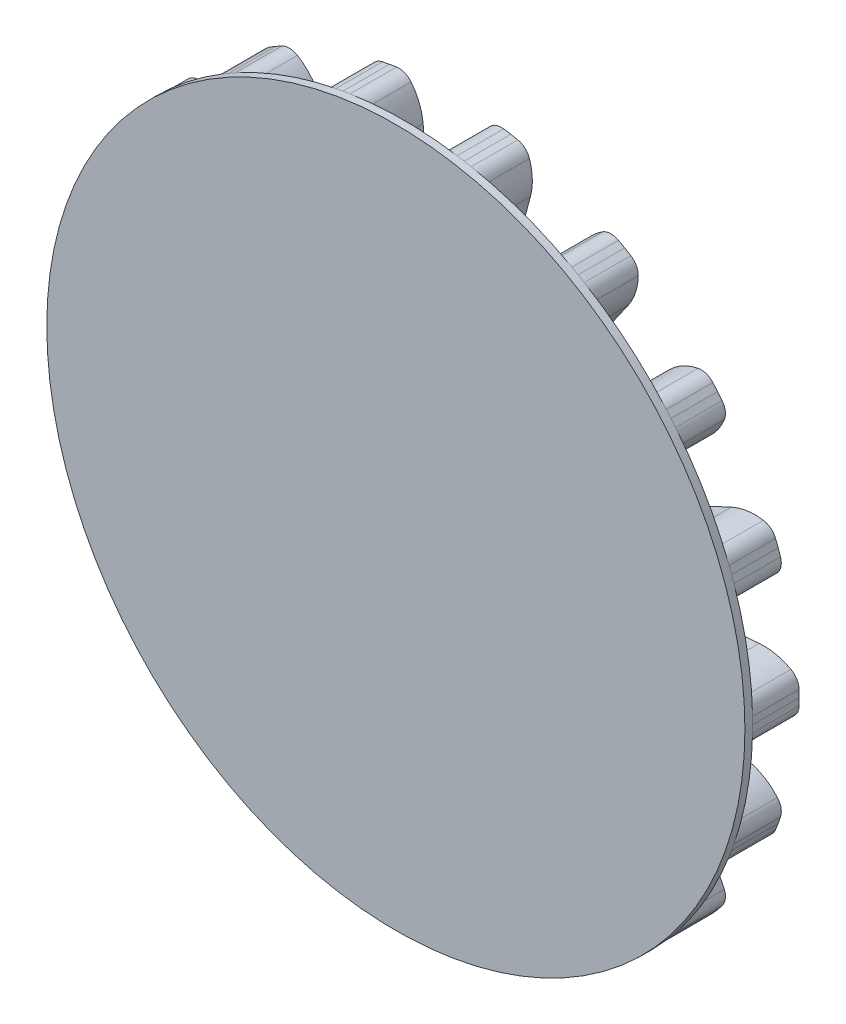
from build123d import *

# Parameters (mm, degrees)
BOSS_EXTRU_4_DEPTH           = 3
CONG_1_R                     = 0.7
CONG_2_R                     = 1
R_P_TITION_CIRCULAIRE1_COUNT = 18
ESQUISSE5_R                  = 2.5
ENL_V_MAT_EXTRU_1_DEPTH      = 32.778381009
ENL_V_MAT_EXTRU_2_DEPTH      = 32.778381009
ESQUISSE7_R                  = 4.018452413
ENL_V_MAT_EXTRU_3_DEPTH      = 10
ESQUISSE8_R                  = 22.5
BOSS_EXTRU_5_DEPTH           = 0.5


with BuildPart() as part:
    # Esquisse4 → Boss.-Extru.4 (new body)
    with BuildSketch(Plane.XY):
        with BuildLine():
            ThreePointArc((17.433407217, -1.525225498), (17.350285074, -2.284208364), (17.234135678, -3.038843109))
            Line((17.234135678, -3.038843109), (0, 0))
            Line((0, 0), (17.234135678, 3.038843109))
            ThreePointArc((17.234135678, 3.038843109), (17.350285074, 2.284208364), (17.433407217, 1.525225498))
            Line((17.433407217, 1.525225498), (19.923893962, 1.743114855))
            ThreePointArc((19.923893962, 1.743114855), (21.273894998, 1.605964155), (22.478584986, 0.981436216))
            Line((22.478584986, 0.981436216), (22.5, 0))
            Line((22.5, 0), (22.478584986, -0.981436216))
            ThreePointArc((22.478584986, -0.981436216), (21.273894998, -1.605964155), (19.923893962, -1.743114855))
            Line((19.923893962, -1.743114855), (17.433407217, -1.525225498))
        make_face()
    extrude(amount=BOSS_EXTRU_4_DEPTH)

    # Congé1
    cong_1_edges = [part.edges().sort_by_distance(p)[0] for p in [
        (17.433407217, 1.525225498, 1.5),
        (17.433407217, -1.525225498, 1.5),
    ]]
    fillet(cong_1_edges, radius=CONG_1_R)

    # Congé2
    cong_2_edges = [part.edges().sort_by_distance(p)[0] for p in [
        (22.478584986, 0.981436216, 1.5),
        (22.478584986, -0.981436216, 1.5),
    ]]
    fillet(cong_2_edges, radius=CONG_2_R)


with BuildPart() as r_p_tition_circulaire1_1:
    # Répétition circulaire1: pattern copy
    add(part.part.rotate(Axis((0, 0, 0), (0, 0, 1)), 1 * 360 / R_P_TITION_CIRCULAIRE1_COUNT))


with BuildPart() as r_p_tition_circulaire1_2:
    # Répétition circulaire1: pattern copy
    add(part.part.rotate(Axis((0, 0, 0), (0, 0, 1)), 2 * 360 / R_P_TITION_CIRCULAIRE1_COUNT))


with BuildPart() as r_p_tition_circulaire1_3:
    # Répétition circulaire1: pattern copy
    add(part.part.rotate(Axis((0, 0, 0), (0, 0, 1)), 3 * 360 / R_P_TITION_CIRCULAIRE1_COUNT))


with BuildPart() as r_p_tition_circulaire1_4:
    # Répétition circulaire1: pattern copy
    add(part.part.rotate(Axis((0, 0, 0), (0, 0, 1)), 4 * 360 / R_P_TITION_CIRCULAIRE1_COUNT))


with BuildPart() as r_p_tition_circulaire1_5:
    # Répétition circulaire1: pattern copy
    add(part.part.rotate(Axis((0, 0, 0), (0, 0, 1)), 5 * 360 / R_P_TITION_CIRCULAIRE1_COUNT))


with BuildPart() as r_p_tition_circulaire1_6:
    # Répétition circulaire1: pattern copy
    add(part.part.rotate(Axis((0, 0, 0), (0, 0, 1)), 6 * 360 / R_P_TITION_CIRCULAIRE1_COUNT))


with BuildPart() as r_p_tition_circulaire1_7:
    # Répétition circulaire1: pattern copy
    add(part.part.rotate(Axis((0, 0, 0), (0, 0, 1)), 7 * 360 / R_P_TITION_CIRCULAIRE1_COUNT))


with BuildPart() as r_p_tition_circulaire1_8:
    # Répétition circulaire1: pattern copy
    add(part.part.rotate(Axis((0, 0, 0), (0, 0, 1)), 8 * 360 / R_P_TITION_CIRCULAIRE1_COUNT))


with BuildPart() as r_p_tition_circulaire1_9:
    # Répétition circulaire1: pattern copy
    add(part.part.rotate(Axis((0, 0, 0), (0, 0, 1)), 9 * 360 / R_P_TITION_CIRCULAIRE1_COUNT))


with BuildPart() as r_p_tition_circulaire1_10:
    # Répétition circulaire1: pattern copy
    add(part.part.rotate(Axis((0, 0, 0), (0, 0, 1)), 10 * 360 / R_P_TITION_CIRCULAIRE1_COUNT))


with BuildPart() as r_p_tition_circulaire1_11:
    # Répétition circulaire1: pattern copy
    add(part.part.rotate(Axis((0, 0, 0), (0, 0, 1)), 11 * 360 / R_P_TITION_CIRCULAIRE1_COUNT))


with BuildPart() as r_p_tition_circulaire1_12:
    # Répétition circulaire1: pattern copy
    add(part.part.rotate(Axis((0, 0, 0), (0, 0, 1)), 12 * 360 / R_P_TITION_CIRCULAIRE1_COUNT))


with BuildPart() as r_p_tition_circulaire1_13:
    # Répétition circulaire1: pattern copy
    add(part.part.rotate(Axis((0, 0, 0), (0, 0, 1)), 13 * 360 / R_P_TITION_CIRCULAIRE1_COUNT))


with BuildPart() as r_p_tition_circulaire1_14:
    # Répétition circulaire1: pattern copy
    add(part.part.rotate(Axis((0, 0, 0), (0, 0, 1)), 14 * 360 / R_P_TITION_CIRCULAIRE1_COUNT))


with BuildPart() as r_p_tition_circulaire1_15:
    # Répétition circulaire1: pattern copy
    add(part.part.rotate(Axis((0, 0, 0), (0, 0, 1)), 15 * 360 / R_P_TITION_CIRCULAIRE1_COUNT))


with BuildPart() as r_p_tition_circulaire1_16:
    # Répétition circulaire1: pattern copy
    add(part.part.rotate(Axis((0, 0, 0), (0, 0, 1)), 16 * 360 / R_P_TITION_CIRCULAIRE1_COUNT))


with BuildPart() as r_p_tition_circulaire1_17:
    # Répétition circulaire1: pattern copy
    add(part.part.rotate(Axis((0, 0, 0), (0, 0, 1)), 17 * 360 / R_P_TITION_CIRCULAIRE1_COUNT))


with BuildPart() as enl_v_mat_extru_1_tool:
    # Esquisse5 → Enlèv. mat.-Extru.1 (new, through all)
    with BuildSketch(Plane.XY.offset(3)):
        Circle(ESQUISSE5_R)
    extrude(amount=-ENL_V_MAT_EXTRU_1_DEPTH)


with BuildPart() as part_1:
    add(part.part)

    # Enlèv. mat.-Extru.1: cut by enl_v_mat_extru_1_tool
    add(enl_v_mat_extru_1_tool.part, mode=Mode.SUBTRACT)


with BuildPart() as r_p_tition_circulaire1_1_1:
    add(r_p_tition_circulaire1_1.part)

    # Enlèv. mat.-Extru.1: cut by enl_v_mat_extru_1_tool
    add(enl_v_mat_extru_1_tool.part, mode=Mode.SUBTRACT)


with BuildPart() as r_p_tition_circulaire1_2_1:
    add(r_p_tition_circulaire1_2.part)

    # Enlèv. mat.-Extru.1: cut by enl_v_mat_extru_1_tool
    add(enl_v_mat_extru_1_tool.part, mode=Mode.SUBTRACT)


with BuildPart() as r_p_tition_circulaire1_3_1:
    add(r_p_tition_circulaire1_3.part)

    # Enlèv. mat.-Extru.1: cut by enl_v_mat_extru_1_tool
    add(enl_v_mat_extru_1_tool.part, mode=Mode.SUBTRACT)


with BuildPart() as r_p_tition_circulaire1_4_1:
    add(r_p_tition_circulaire1_4.part)

    # Enlèv. mat.-Extru.1: cut by enl_v_mat_extru_1_tool
    add(enl_v_mat_extru_1_tool.part, mode=Mode.SUBTRACT)


with BuildPart() as r_p_tition_circulaire1_5_1:
    add(r_p_tition_circulaire1_5.part)

    # Enlèv. mat.-Extru.1: cut by enl_v_mat_extru_1_tool
    add(enl_v_mat_extru_1_tool.part, mode=Mode.SUBTRACT)


with BuildPart() as r_p_tition_circulaire1_6_1:
    add(r_p_tition_circulaire1_6.part)

    # Enlèv. mat.-Extru.1: cut by enl_v_mat_extru_1_tool
    add(enl_v_mat_extru_1_tool.part, mode=Mode.SUBTRACT)


with BuildPart() as r_p_tition_circulaire1_7_1:
    add(r_p_tition_circulaire1_7.part)

    # Enlèv. mat.-Extru.1: cut by enl_v_mat_extru_1_tool
    add(enl_v_mat_extru_1_tool.part, mode=Mode.SUBTRACT)


with BuildPart() as r_p_tition_circulaire1_8_1:
    add(r_p_tition_circulaire1_8.part)

    # Enlèv. mat.-Extru.1: cut by enl_v_mat_extru_1_tool
    add(enl_v_mat_extru_1_tool.part, mode=Mode.SUBTRACT)


with BuildPart() as r_p_tition_circulaire1_9_1:
    add(r_p_tition_circulaire1_9.part)

    # Enlèv. mat.-Extru.1: cut by enl_v_mat_extru_1_tool
    add(enl_v_mat_extru_1_tool.part, mode=Mode.SUBTRACT)


with BuildPart() as r_p_tition_circulaire1_10_1:
    add(r_p_tition_circulaire1_10.part)

    # Enlèv. mat.-Extru.1: cut by enl_v_mat_extru_1_tool
    add(enl_v_mat_extru_1_tool.part, mode=Mode.SUBTRACT)


with BuildPart() as r_p_tition_circulaire1_11_1:
    add(r_p_tition_circulaire1_11.part)

    # Enlèv. mat.-Extru.1: cut by enl_v_mat_extru_1_tool
    add(enl_v_mat_extru_1_tool.part, mode=Mode.SUBTRACT)


with BuildPart() as r_p_tition_circulaire1_12_1:
    add(r_p_tition_circulaire1_12.part)

    # Enlèv. mat.-Extru.1: cut by enl_v_mat_extru_1_tool
    add(enl_v_mat_extru_1_tool.part, mode=Mode.SUBTRACT)


with BuildPart() as r_p_tition_circulaire1_13_1:
    add(r_p_tition_circulaire1_13.part)

    # Enlèv. mat.-Extru.1: cut by enl_v_mat_extru_1_tool
    add(enl_v_mat_extru_1_tool.part, mode=Mode.SUBTRACT)


with BuildPart() as r_p_tition_circulaire1_14_1:
    add(r_p_tition_circulaire1_14.part)

    # Enlèv. mat.-Extru.1: cut by enl_v_mat_extru_1_tool
    add(enl_v_mat_extru_1_tool.part, mode=Mode.SUBTRACT)


with BuildPart() as r_p_tition_circulaire1_15_1:
    add(r_p_tition_circulaire1_15.part)

    # Enlèv. mat.-Extru.1: cut by enl_v_mat_extru_1_tool
    add(enl_v_mat_extru_1_tool.part, mode=Mode.SUBTRACT)


with BuildPart() as r_p_tition_circulaire1_16_1:
    add(r_p_tition_circulaire1_16.part)

    # Enlèv. mat.-Extru.1: cut by enl_v_mat_extru_1_tool
    add(enl_v_mat_extru_1_tool.part, mode=Mode.SUBTRACT)


with BuildPart() as r_p_tition_circulaire1_17_1:
    add(r_p_tition_circulaire1_17.part)

    # Enlèv. mat.-Extru.1: cut by enl_v_mat_extru_1_tool
    add(enl_v_mat_extru_1_tool.part, mode=Mode.SUBTRACT)


with BuildPart() as enl_v_mat_extru_2_tool:
    # Esquisse6 → Enlèv. mat.-Extru.2 (new, through all)
    with BuildSketch(Plane.XY.offset(3)):
        with BuildLine():
            Line((2.326636597, -14.696627841), (3.459323403, -2.287472159))
            add(Edge.make_bspline(
                [(3.459323403, -2.287472159), (3.509578647, -1.618115314), (3.610089136, -0.279401623), (3.193486845, 5.400258865), (2.634713817, 10.38131394), (2.150623403, 14.696627841)],
                knots=[0, 0, 0, 0, 0.117897148, 0.235794296, 1, 1, 1, 1], degree=3))
            add(Edge.make_bspline(
                [(2.150623403, 14.696627841), (2.095752738, 14.957223177), (1.986004569, 15.478446335), (1.479240929, 16.11915433), (0.795253054, 16.542773464), (0, 16.690346959), (-0.795253054, 16.542773464), (-1.479240929, 16.11915433), (-1.986004569, 15.478446335), (-2.095752738, 14.957223177), (-2.150623403, 14.696627841)],
                knots=[0, 0, 0, 0, 0.124995376, 0.250006333, 0.375000133, 0.5, 0.624999867, 0.749993667, 0.875004624, 1, 1, 1, 1], degree=3))
            Line((-2.150623403, 14.696627841), (-3.459323403, 2.287472159))
            add(Edge.make_bspline(
                [(-3.459323403, 2.287472159), (-3.509578647, 1.618115314), (-3.610089136, 0.279401623), (-3.193486845, -5.400258865), (-2.634713817, -10.38131394), (-2.150623403, -14.696627841)],
                knots=[0, 0, 0, 0, 0.117897148, 0.235794296, 1, 1, 1, 1], degree=3))
            add(Edge.make_bspline(
                [(-2.150623403, -14.696627841), (-2.093507352, -14.967887113), (-1.97926813, -15.510439471), (-1.451766994, -16.177366156), (-0.739789354, -16.618320393), (0.088006597, -16.771932808), (0.915802548, -16.618320393), (1.627780189, -16.177366156), (2.155281325, -15.510439471), (2.269520547, -14.967887113), (2.326636597, -14.696627841)],
                knots=[0, 0, 0, 0, 0.124995376, 0.250006333, 0.375000133, 0.5, 0.624999867, 0.749993667, 0.875004624, 1, 1, 1, 1], degree=3))
        make_face()
    extrude(amount=-ENL_V_MAT_EXTRU_2_DEPTH)


with BuildPart() as part_2:
    add(part_1.part)

    # Enlèv. mat.-Extru.2: cut by enl_v_mat_extru_2_tool
    add(enl_v_mat_extru_2_tool.part, mode=Mode.SUBTRACT)


with BuildPart() as r_p_tition_circulaire1_1_2:
    add(r_p_tition_circulaire1_1_1.part)

    # Enlèv. mat.-Extru.2: cut by enl_v_mat_extru_2_tool
    add(enl_v_mat_extru_2_tool.part, mode=Mode.SUBTRACT)


with BuildPart() as r_p_tition_circulaire1_2_2:
    add(r_p_tition_circulaire1_2_1.part)

    # Enlèv. mat.-Extru.2: cut by enl_v_mat_extru_2_tool
    add(enl_v_mat_extru_2_tool.part, mode=Mode.SUBTRACT)


with BuildPart() as r_p_tition_circulaire1_3_2:
    add(r_p_tition_circulaire1_3_1.part)

    # Enlèv. mat.-Extru.2: cut by enl_v_mat_extru_2_tool
    add(enl_v_mat_extru_2_tool.part, mode=Mode.SUBTRACT)


with BuildPart() as r_p_tition_circulaire1_4_2:
    add(r_p_tition_circulaire1_4_1.part)

    # Enlèv. mat.-Extru.2: cut by enl_v_mat_extru_2_tool
    add(enl_v_mat_extru_2_tool.part, mode=Mode.SUBTRACT)


with BuildPart() as r_p_tition_circulaire1_5_2:
    add(r_p_tition_circulaire1_5_1.part)

    # Enlèv. mat.-Extru.2: cut by enl_v_mat_extru_2_tool
    add(enl_v_mat_extru_2_tool.part, mode=Mode.SUBTRACT)


with BuildPart() as r_p_tition_circulaire1_6_2:
    add(r_p_tition_circulaire1_6_1.part)

    # Enlèv. mat.-Extru.2: cut by enl_v_mat_extru_2_tool
    add(enl_v_mat_extru_2_tool.part, mode=Mode.SUBTRACT)


with BuildPart() as r_p_tition_circulaire1_7_2:
    add(r_p_tition_circulaire1_7_1.part)

    # Enlèv. mat.-Extru.2: cut by enl_v_mat_extru_2_tool
    add(enl_v_mat_extru_2_tool.part, mode=Mode.SUBTRACT)


with BuildPart() as r_p_tition_circulaire1_8_2:
    add(r_p_tition_circulaire1_8_1.part)

    # Enlèv. mat.-Extru.2: cut by enl_v_mat_extru_2_tool
    add(enl_v_mat_extru_2_tool.part, mode=Mode.SUBTRACT)


with BuildPart() as r_p_tition_circulaire1_9_2:
    add(r_p_tition_circulaire1_9_1.part)

    # Enlèv. mat.-Extru.2: cut by enl_v_mat_extru_2_tool
    add(enl_v_mat_extru_2_tool.part, mode=Mode.SUBTRACT)


with BuildPart() as r_p_tition_circulaire1_10_2:
    add(r_p_tition_circulaire1_10_1.part)

    # Enlèv. mat.-Extru.2: cut by enl_v_mat_extru_2_tool
    add(enl_v_mat_extru_2_tool.part, mode=Mode.SUBTRACT)


with BuildPart() as r_p_tition_circulaire1_11_2:
    add(r_p_tition_circulaire1_11_1.part)

    # Enlèv. mat.-Extru.2: cut by enl_v_mat_extru_2_tool
    add(enl_v_mat_extru_2_tool.part, mode=Mode.SUBTRACT)


with BuildPart() as r_p_tition_circulaire1_12_2:
    add(r_p_tition_circulaire1_12_1.part)

    # Enlèv. mat.-Extru.2: cut by enl_v_mat_extru_2_tool
    add(enl_v_mat_extru_2_tool.part, mode=Mode.SUBTRACT)


with BuildPart() as r_p_tition_circulaire1_13_2:
    add(r_p_tition_circulaire1_13_1.part)

    # Enlèv. mat.-Extru.2: cut by enl_v_mat_extru_2_tool
    add(enl_v_mat_extru_2_tool.part, mode=Mode.SUBTRACT)


with BuildPart() as r_p_tition_circulaire1_14_2:
    add(r_p_tition_circulaire1_14_1.part)

    # Enlèv. mat.-Extru.2: cut by enl_v_mat_extru_2_tool
    add(enl_v_mat_extru_2_tool.part, mode=Mode.SUBTRACT)


with BuildPart() as r_p_tition_circulaire1_15_2:
    add(r_p_tition_circulaire1_15_1.part)

    # Enlèv. mat.-Extru.2: cut by enl_v_mat_extru_2_tool
    add(enl_v_mat_extru_2_tool.part, mode=Mode.SUBTRACT)


with BuildPart() as r_p_tition_circulaire1_16_2:
    add(r_p_tition_circulaire1_16_1.part)

    # Enlèv. mat.-Extru.2: cut by enl_v_mat_extru_2_tool
    add(enl_v_mat_extru_2_tool.part, mode=Mode.SUBTRACT)


with BuildPart() as r_p_tition_circulaire1_17_2:
    add(r_p_tition_circulaire1_17_1.part)

    # Enlèv. mat.-Extru.2: cut by enl_v_mat_extru_2_tool
    add(enl_v_mat_extru_2_tool.part, mode=Mode.SUBTRACT)


with BuildPart() as enl_v_mat_extru_3_tool:
    # Esquisse7 → Enlèv. mat.-Extru.3 (new body)
    with BuildSketch(Plane.XY.offset(3)):
        Circle(ESQUISSE7_R)
    extrude(amount=-ENL_V_MAT_EXTRU_3_DEPTH)


with BuildPart() as part_3:
    add(part_2.part)

    # Enlèv. mat.-Extru.3: cut by enl_v_mat_extru_3_tool
    add(enl_v_mat_extru_3_tool.part, mode=Mode.SUBTRACT)



with BuildPart() as r_p_tition_circulaire1_1_3:
    add(r_p_tition_circulaire1_1_2.part)

    # Enlèv. mat.-Extru.3: cut by enl_v_mat_extru_3_tool
    add(enl_v_mat_extru_3_tool.part, mode=Mode.SUBTRACT)


with BuildPart() as r_p_tition_circulaire1_2_3:
    add(r_p_tition_circulaire1_2_2.part)

    # Enlèv. mat.-Extru.3: cut by enl_v_mat_extru_3_tool
    add(enl_v_mat_extru_3_tool.part, mode=Mode.SUBTRACT)


with BuildPart() as r_p_tition_circulaire1_8_3:
    add(r_p_tition_circulaire1_8_2.part)

    # Enlèv. mat.-Extru.3: cut by enl_v_mat_extru_3_tool
    add(enl_v_mat_extru_3_tool.part, mode=Mode.SUBTRACT)


with BuildPart() as r_p_tition_circulaire1_9_3:
    add(r_p_tition_circulaire1_9_2.part)

    # Enlèv. mat.-Extru.3: cut by enl_v_mat_extru_3_tool
    add(enl_v_mat_extru_3_tool.part, mode=Mode.SUBTRACT)


with BuildPart() as r_p_tition_circulaire1_10_3:
    add(r_p_tition_circulaire1_10_2.part)

    # Enlèv. mat.-Extru.3: cut by enl_v_mat_extru_3_tool
    add(enl_v_mat_extru_3_tool.part, mode=Mode.SUBTRACT)


with BuildPart() as r_p_tition_circulaire1_11_3:
    add(r_p_tition_circulaire1_11_2.part)

    # Enlèv. mat.-Extru.3: cut by enl_v_mat_extru_3_tool
    add(enl_v_mat_extru_3_tool.part, mode=Mode.SUBTRACT)


with BuildPart() as r_p_tition_circulaire1_17_3:
    add(r_p_tition_circulaire1_17_2.part)

    # Enlèv. mat.-Extru.3: cut by enl_v_mat_extru_3_tool
    add(enl_v_mat_extru_3_tool.part, mode=Mode.SUBTRACT)


with BuildPart() as part_4:
    add(part_3.part)

    add(r_p_tition_circulaire1_1_3.part)  # Boss.-Extru.5 merges Répétition circulaire1_1

    add(r_p_tition_circulaire1_2_3.part)  # Boss.-Extru.5 merges Répétition circulaire1_2

    add(r_p_tition_circulaire1_3_2.part)  # Boss.-Extru.5 merges Répétition circulaire1_3

    add(r_p_tition_circulaire1_4_2.part)  # Boss.-Extru.5 merges Répétition circulaire1_4

    add(r_p_tition_circulaire1_5_2.part)  # Boss.-Extru.5 merges Répétition circulaire1_5

    add(r_p_tition_circulaire1_6_2.part)  # Boss.-Extru.5 merges Répétition circulaire1_6

    add(r_p_tition_circulaire1_7_2.part)  # Boss.-Extru.5 merges Répétition circulaire1_7

    add(r_p_tition_circulaire1_8_3.part)  # Boss.-Extru.5 merges Répétition circulaire1_8

    add(r_p_tition_circulaire1_9_3.part)  # Boss.-Extru.5 merges Répétition circulaire1_9

    add(r_p_tition_circulaire1_10_3.part)  # Boss.-Extru.5 merges Répétition circulaire1_10

    add(r_p_tition_circulaire1_11_3.part)  # Boss.-Extru.5 merges Répétition circulaire1_11

    add(r_p_tition_circulaire1_12_2.part)  # Boss.-Extru.5 merges Répétition circulaire1_12

    add(r_p_tition_circulaire1_13_2.part)  # Boss.-Extru.5 merges Répétition circulaire1_13

    add(r_p_tition_circulaire1_14_2.part)  # Boss.-Extru.5 merges Répétition circulaire1_14

    add(r_p_tition_circulaire1_15_2.part)  # Boss.-Extru.5 merges Répétition circulaire1_15

    add(r_p_tition_circulaire1_16_2.part)  # Boss.-Extru.5 merges Répétition circulaire1_16

    add(r_p_tition_circulaire1_17_3.part)  # Boss.-Extru.5 merges Répétition circulaire1_17
    # Esquisse8 → Boss.-Extru.5 (add)
    with BuildSketch(Plane.XY.offset(3)):
        Circle(ESQUISSE8_R)
    extrude(amount=BOSS_EXTRU_5_DEPTH)


solid = part_4.part
